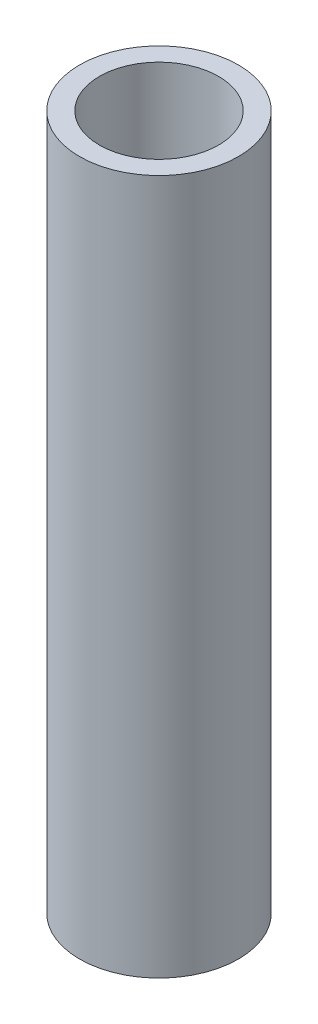
from build123d import *

# Parameters (mm, degrees)
SKETCH_1_R      = 8
SKETCH_1_R_2    = 6
EXTRUDE_1_DEPTH = 70


with BuildPart() as part:
    # 草图1 → 拉伸-薄壁1 (new body)
    with BuildSketch(Plane(origin=(0, 0, 0), x_dir=(1, 0, 0), z_dir=(0, 1, 0))):
        Circle(SKETCH_1_R)
        Circle(SKETCH_1_R_2, mode=Mode.SUBTRACT)
    extrude(amount=-EXTRUDE_1_DEPTH)


solid = part.part
